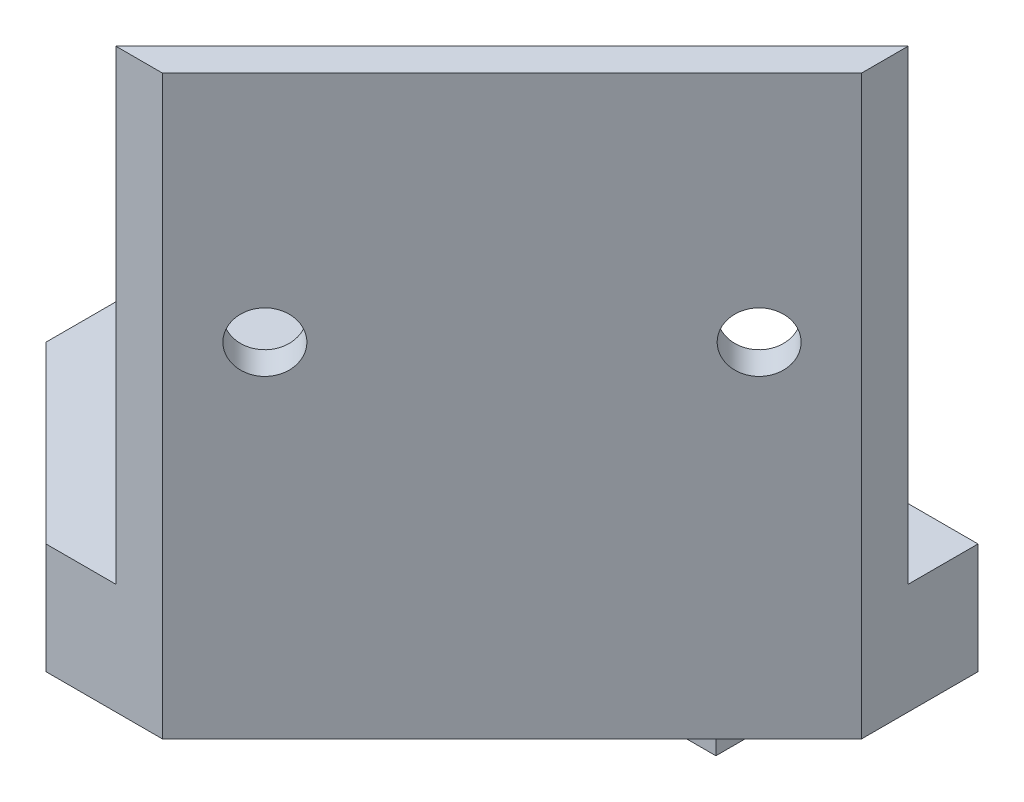
from build123d import *

# Parameters (mm, degrees)
SKETCH1_W                            = 40
SKETCH1_H                            = 10
BOSS_EXTRUDE1_DEPTH                  = 7.5
CBORE_FOR_M3_SHCS1_AT_2_COUNT        = 2
CBORE_FOR_M3_SHCS1_AT_2_PITCH        = 30
SKETCH4_W                            = 55
SKETCH4_H                            = 9.5
BOSS_EXTRUDE2_DEPTH                  = 40
BOSS_EXTRUDE3_DEPTH                  = 40
CUT_EXTRUDE1_DEPTH                   = 20.5
F_5_1_5_1_DIAMETER_HOLE1_D           = 5.1
F_5_1_5_1_DIAMETER_HOLE1_DEPTH       = 2.828427125
F_5_1_5_1_DIAMETER_HOLE1_CSINK_D     = 5.15
F_5_1_5_1_DIAMETER_HOLE1_CSINK_ANGLE = 90
CUT_EXTRUDE2_DEPTH                   = 20.5


with BuildPart() as part:
    # Sketch1 → Boss-Extrude1 (new body)
    with BuildSketch(Plane.XY):
        with Locations((20, -5)):
            Rectangle(SKETCH1_W, SKETCH1_H)
    extrude(amount=BOSS_EXTRUDE1_DEPTH)

    # Sketch3 → CBORE for M3 SHCS1 (revolve, cut)
    with BuildSketch(Plane(origin=(35, -5, 7.5), x_dir=(0, -1, 0), z_dir=(1, 0, 0))):
        Polygon((0, 0), (0, 7.5), (1.7, 7.5), (1.7, 3), (3.25, 3), (3.25, 0.025), (3.275, 0), align=None)
    cbore_for_m3_shcs1 = revolve(axis=Axis((35, -5, 13.85), (0, 0, -1)), mode=Mode.SUBTRACT)

    # CBORE for M3 SHCS1 at 2: CBORE for M3 SHCS1 ×2
    with Locations(*[(-i * CBORE_FOR_M3_SHCS1_AT_2_PITCH, 0, 0) for i in range(1, CBORE_FOR_M3_SHCS1_AT_2_COUNT)]):
        add(cbore_for_m3_shcs1, mode=Mode.SUBTRACT)

    # Sketch4 → Boss-Extrude2 (add)
    with BuildSketch(Plane.XY):
        with Locations((27.5, 4.75)):
            Rectangle(SKETCH4_W, SKETCH4_H)
    extrude(amount=BOSS_EXTRUDE2_DEPTH)

    # Sketch5 → Boss-Extrude3 (add)
    with BuildSketch(Plane(origin=(0, 9.5, 0), x_dir=(1, 0, 0), z_dir=(0, 1, 0))):
        Polygon((55, -10), (25, -40), (21, -40), (55, -6), align=None)
    extrude(amount=BOSS_EXTRUDE3_DEPTH)

    # Sketch7 → Cut-Extrude1 (cut, through all)
    with BuildSketch(Plane(origin=(0, 9.5, 0), x_dir=(1, 0, 0), z_dir=(0, 1, 0))):
        Polygon((55, -10), (25, -40), (55, -40), align=None)
    extrude(amount=-CUT_EXTRUDE1_DEPTH, mode=Mode.SUBTRACT)

    # Ø5.1 (5.1) Diameter Hole1
    with Locations(Plane(origin=(30.5, 0, 30.5), x_dir=(-0.707106781, 0, 0.707106781), z_dir=(-0.707106781, 0, -0.707106781))):
        with Locations((4.393398282, 29.5), (-25.606601718, 29.5)):
            CounterSinkHole(F_5_1_5_1_DIAMETER_HOLE1_D / 2, F_5_1_5_1_DIAMETER_HOLE1_CSINK_D / 2, depth=F_5_1_5_1_DIAMETER_HOLE1_DEPTH, counter_sink_angle=F_5_1_5_1_DIAMETER_HOLE1_CSINK_ANGLE)

    # Sketch11 → Cut-Extrude2 (cut, through all)
    with BuildSketch(Plane(origin=(0, 9.5, 0), x_dir=(1, 0, 0), z_dir=(0, 1, 0))):
        Polygon((0, -25), (0, -40), (15, -40), align=None)
    extrude(amount=-CUT_EXTRUDE2_DEPTH, mode=Mode.SUBTRACT)


solid = part.part
